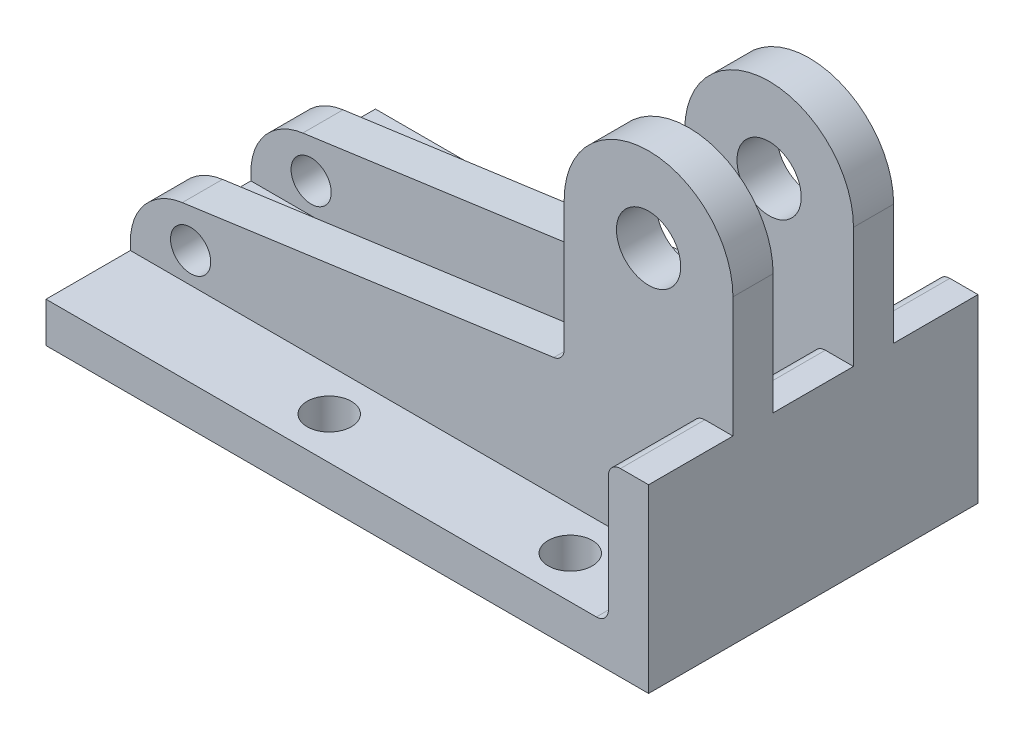
from build123d import *

# Parameters (mm, degrees)
EXTRUDE_1_DEPTH          = 82
FILLET_1_R               = 3
EXTRUDE_2_DEPTH          = 10
SKETCH_3_R               = 8
SKETCH_3_R_2             = 5
CUT_EXTRUDE_1_DEPTH      = 42
CUT_EXTRUDE_1_DEPTH_BACK = 42
FILLET_2_R               = 15
SKETCH_4_R               = 5.5
CUT_EXTRUDE_2_DEPTH      = 97
CUT_EXTRUDE_2_DEPTH_BACK = 1
FILLET_3_R               = 3
FILLET_4_R               = 3


with BuildPart() as part:
    # 스케치1 → 보스-돌출1 (new body)
    with BuildSketch(Plane.XY):
        Polygon((0, 0), (-150, 0), (-150, 10), (-10, 10), (-10, 45), (0, 45), align=None)
    extrude(amount=-EXTRUDE_1_DEPTH)

    # 필렛1
    fillet_1_edges = [part.edges().sort_by_distance(p)[0] for p in [
        (-10, 45, -41),
    ]]
    fillet(fillet_1_edges, radius=FILLET_1_R)

    # 스케치2 → 보스-돌출2 (add)
    with BuildSketch(Plane(origin=(0, 0, -61), x_dir=(-1, 0, 0), z_dir=(0, 0, -1))):
        with BuildLine():
            Line((150, 0), (150, 25))
            Line((150, 25), (42, 40))
            Line((42, 40), (42, 75))
            ThreePointArc((42, 75), (21, 96), (0, 75))
            Line((0, 75), (0, 0))
            Line((0, 0), (150, 0))
        make_face()
    extrude_2 = extrude(amount=-EXTRUDE_2_DEPTH)

    # 대칭 복사1: 보스-돌출2 across plane
    add(extrude_2.mirror(Plane.XY.offset(-41)))

    # 스케치3 → 컷-돌출1 (cut, two sides)
    with BuildSketch(Plane.XY.offset(-41)) as cut_extrude_1_sk:
        with Locations((-21, 75)):
            Circle(SKETCH_3_R)
        with Locations((-135, 17.5)):
            Circle(SKETCH_3_R_2)
    extrude(amount=CUT_EXTRUDE_1_DEPTH, mode=Mode.SUBTRACT)
    extrude(cut_extrude_1_sk.sketch, amount=-CUT_EXTRUDE_1_DEPTH_BACK, mode=Mode.SUBTRACT)

    # 필렛2
    fillet_2_edges = [part.edges().sort_by_distance(p)[0] for p in [
        (-150, 25, -56),
        (-150, 25, -26),
    ]]
    fillet(fillet_2_edges, radius=FILLET_2_R)

    # 스케치4 → 컷-돌출2 (cut, two sides)
    with BuildSketch(Plane(origin=(0, 0, 0), x_dir=(1, 0, 0), z_dir=(0, 1, 0))) as cut_extrude_2_sk:
        with Locations((-30, 71.5)):
            Circle(SKETCH_4_R)
        with Locations((-90, 71.5)):
            Circle(SKETCH_4_R)
        with Locations((-30, 10.5)):
            Circle(SKETCH_4_R)
        with Locations((-90, 10.5)):
            Circle(SKETCH_4_R)
    extrude(amount=CUT_EXTRUDE_2_DEPTH, mode=Mode.SUBTRACT)
    extrude(cut_extrude_2_sk.sketch, amount=-CUT_EXTRUDE_2_DEPTH_BACK, mode=Mode.SUBTRACT)

    # 필렛3
    fillet_3_edges = [part.edges().sort_by_distance(p)[0] for p in [
        (-10, 10, -71.5),
        (-10, 10, -41),
        (-10, 10, -10.5),
    ]]
    fillet(fillet_3_edges, radius=FILLET_3_R)

    # 필렛4
    fillet_4_edges = [part.edges().sort_by_distance(p)[0] for p in [
        (-42, 40, -56),
        (-42, 40, -26),
    ]]
    fillet(fillet_4_edges, radius=FILLET_4_R)


solid = part.part
